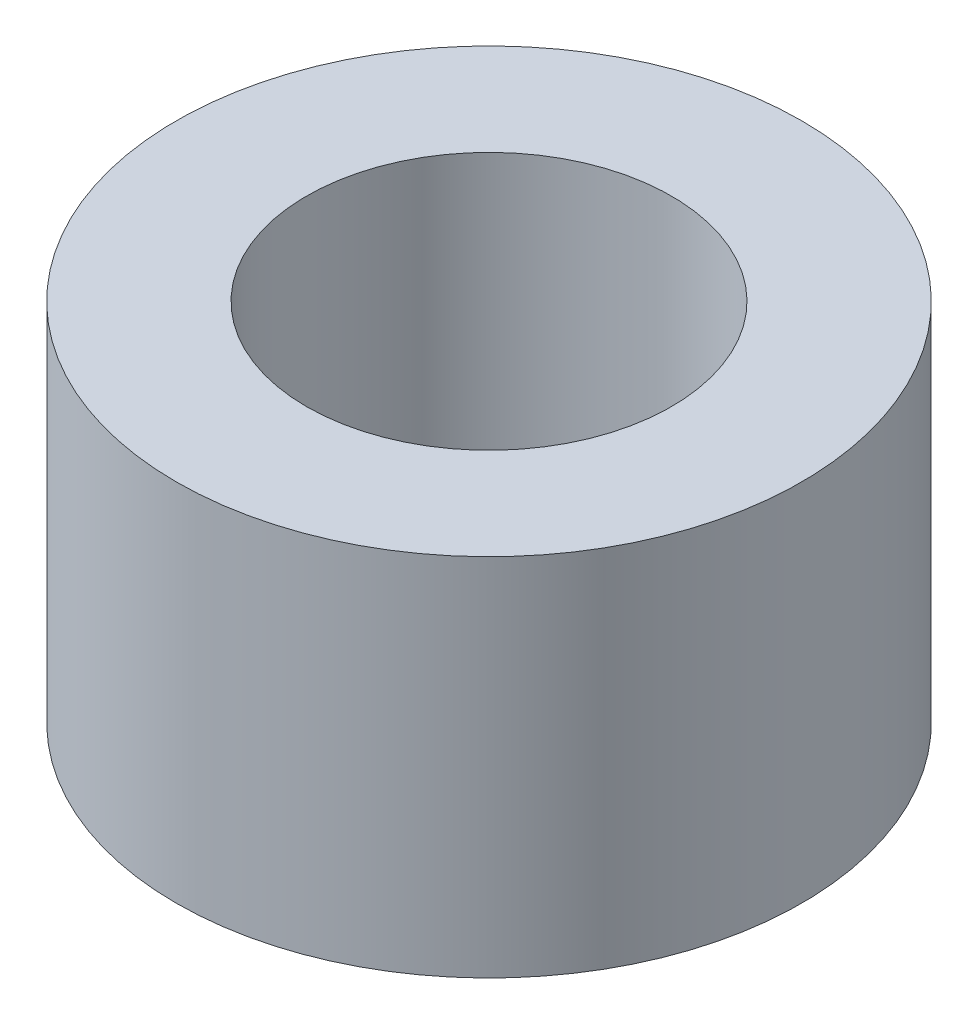
from build123d import *

# Parameters (mm, degrees)
ESQUISSE1_W = 1.25
ESQUISSE1_H = 3.5


with BuildPart() as part:
    # Esquisse1 → Révolution1 (revolve)
    with BuildSketch(Plane(origin=(0, 0, 0), x_dir=(0, 0, -1), z_dir=(1, 0, 0))):
        with Locations((2.375, 1.75)):
            Rectangle(ESQUISSE1_W, ESQUISSE1_H)
    revolve(axis=Axis((0, 3.779585799, 0), (0, -1, 0)))


solid = part.part
